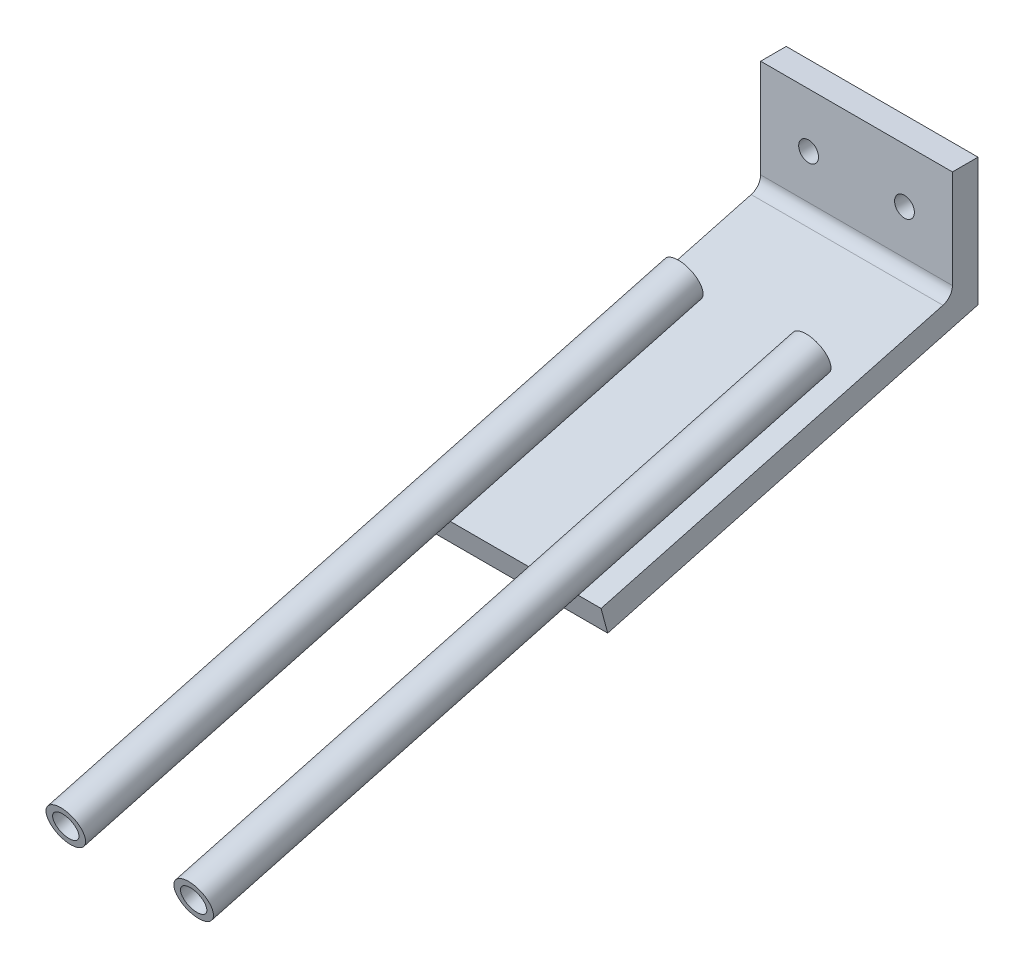
from build123d import *

# Parameters (mm, degrees)
BOSS_EXTRUDE1_DEPTH        = 15
SKETCH2_R                  = 3
SKETCH2_R_2                = 2
BOSS_EXTRUDE2_DEPTH        = 40
BOSS_EXTRUDE2_DEPTH_BACK   = 60
BOSS_EXTRUDE2_2_DEPTH      = 40
BOSS_EXTRUDE2_2_DEPTH_BACK = 60
SKETCH4_R                  = 1.55
CUT_EXTRUDE1_DEPTH         = 5
FILLET1_R                  = 2


with BuildPart() as part:
    # Sketch1 → Boss-Extrude1 (new body, symmetric)
    with BuildSketch(Plane.YZ):
        Polygon((-11.656809702, 58.958619281), (3.069307952, 4), (20, 4), (20, 0), (0, 0), (-15.520513007, 57.923343101), align=None)
    extrude(amount=BOSS_EXTRUDE1_DEPTH, both=True)

    # Sketch4 → Cut-Extrude1 (cut, through all)
    with BuildSketch(Plane.XY.offset(4)):
        with Locations((-7.5, 11.534653976)):
            Circle(SKETCH4_R)
        with Locations((7.5, 11.534653976)):
            Circle(SKETCH4_R)
    extrude(amount=-CUT_EXTRUDE1_DEPTH, mode=Mode.SUBTRACT)

    # Fillet1
    fillet1_edges = [part.edges().sort_by_distance(p)[0] for p in [
        (0, 3.069307952, 4),
    ]]
    fillet(fillet1_edges, radius=FILLET1_R)


with BuildPart() as body_2:
    # Sketch2 → Boss-Extrude2 (new body, two sides)
    with BuildSketch(Plane(origin=(0, -15.520513007, 57.923343101), x_dir=(-1, 0, 0), z_dir=(0, 0.258819045, -0.965925826))) as boss_extrude2_sk:
        with Locations((-10, 7)):
            Circle(SKETCH2_R)
        with Locations((-10, 7)):
            Circle(SKETCH2_R_2, mode=Mode.SUBTRACT)
    extrude(amount=BOSS_EXTRUDE2_DEPTH)
    extrude(boss_extrude2_sk.sketch, amount=-BOSS_EXTRUDE2_DEPTH_BACK)


with BuildPart() as body_3:
    # Sketch2 → Boss-Extrude2 2 (new body, two sides)
    with BuildSketch(Plane(origin=(0, -15.520513007, 57.923343101), x_dir=(-1, 0, 0), z_dir=(0, 0.258819045, -0.965925826))) as boss_extrude2_2_sk:
        with Locations((10, 7)):
            Circle(SKETCH2_R)
        with Locations((10, 7)):
            Circle(SKETCH2_R_2, mode=Mode.SUBTRACT)
    extrude(amount=BOSS_EXTRUDE2_2_DEPTH)
    extrude(boss_extrude2_2_sk.sketch, amount=-BOSS_EXTRUDE2_2_DEPTH_BACK)


solid = Compound([part.part, body_2.part, body_3.part])
